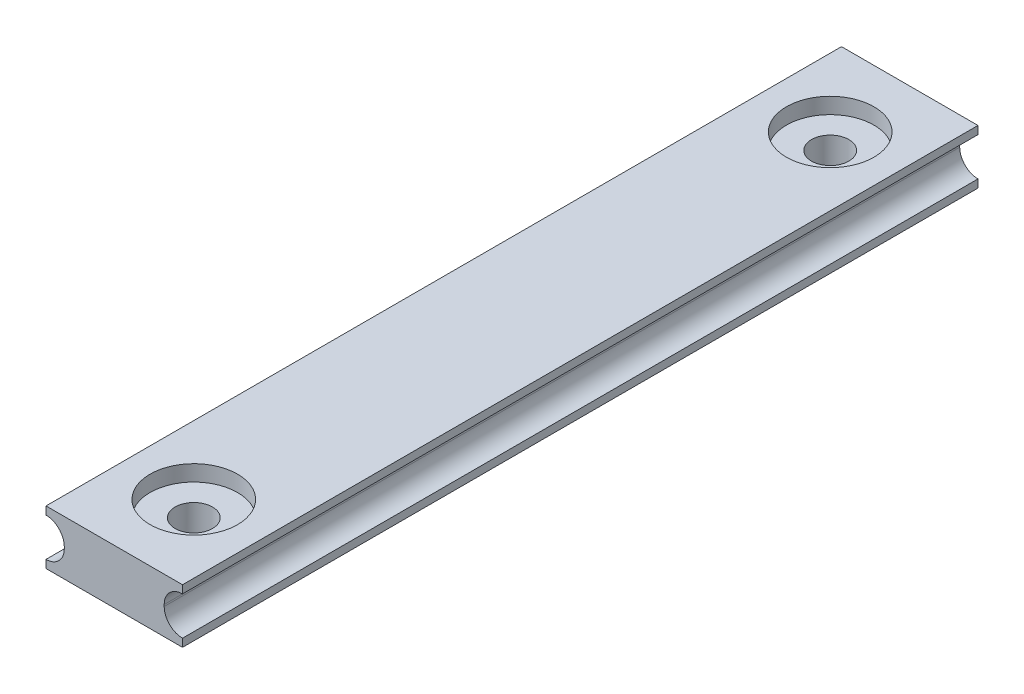
from build123d import *

# Parameters (mm, degrees)
BOSS_EXTRUDE1_DEPTH = 25
SKETCH2_R           = 1.175
CUT_EXTRUDE1_DEPTH  = 4.41
SKETCH3_R           = 2.75
CUT_EXTRUDE2_DEPTH  = 1


with BuildPart() as part:
    # Sketch1 → Boss-Extrude1 (new body, symmetric)
    with BuildSketch(Plane.XY):
        with BuildLine():
            Line((-3.14, 0.055), (-3.14, -0.055))
            ThreePointArc((-3.14, -0.055), (-3.476827202, -0.868172798), (-4.29, -1.205))
            Line((-4.29, -1.205), (-4.29, -1.705))
            Line((-4.29, -1.705), (4.29, -1.705))
            Line((4.29, -1.705), (4.29, -1.205))
            ThreePointArc((4.29, -1.205), (3.476827202, -0.868172798), (3.14, -0.055))
            Line((3.14, -0.055), (3.14, 0.055))
            ThreePointArc((3.14, 0.055), (3.476827202, 0.868172798), (4.29, 1.205))
            Line((4.29, 1.205), (4.29, 1.705))
            Line((4.29, 1.705), (-4.29, 1.705))
            Line((-4.29, 1.705), (-4.29, 1.205))
            ThreePointArc((-4.29, 1.205), (-3.476827202, 0.868172798), (-3.14, 0.055))
        make_face()
    extrude(amount=BOSS_EXTRUDE1_DEPTH, both=True)

    # Sketch2 → Cut-Extrude1 (cut, through all)
    with BuildSketch(Plane(origin=(0, 1.705, 0), x_dir=(1, 0, 0), z_dir=(0, 1, 0))):
        with Locations((0, 20)):
            Circle(SKETCH2_R)
    cut_extrude1 = extrude(amount=-CUT_EXTRUDE1_DEPTH, mode=Mode.SUBTRACT)

    # Sketch3 → Cut-Extrude2 (cut)
    with BuildSketch(Plane(origin=(0, 1.705, 0), x_dir=(1, 0, 0), z_dir=(0, 1, 0))):
        with Locations((0, 20)):
            Circle(SKETCH3_R)
    cut_extrude2 = extrude(amount=-CUT_EXTRUDE2_DEPTH, mode=Mode.SUBTRACT)

    # Mirror1: Cut-Extrude1, Cut-Extrude2 across plane
    add(cut_extrude1.mirror(Plane.XY), mode=Mode.SUBTRACT)
    add(cut_extrude2.mirror(Plane.XY), mode=Mode.SUBTRACT)


solid = part.part
